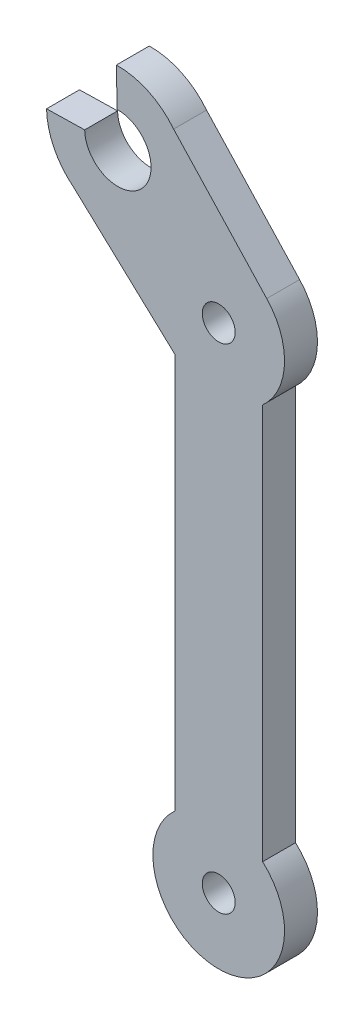
from build123d import *

# Parameters (mm, degrees)
ESQUISSE1_R        = 1.5
BOSS_EXTRU_1_DEPTH = 3


with BuildPart() as part:
    # Esquisse1 → Boss.-Extru.1 (new body)
    with BuildSketch(Plane.XY):
        with BuildLine():
            Line((0, 40.527864045), (0, 4.472135955))
            ThreePointArc((0, 4.472135955), (4, -6), (8, 4.472135955))
            Line((8, 4.472135955), (8, 40.527864045))
            ThreePointArc((8, 40.527864045), (9.994318296, 44.738947964), (8.373640852, 49.107464631))
            Line((8.373640852, 49.107464631), (-0.107464631, 58.241283406))
            ThreePointArc((-0.107464631, 58.241283406), (-2.431884599, 60.07708187), (-5.329514747, 60.690941556))
            Line((-5.329514747, 60.690941556), (-5.256204762, 57.21671493))
            ThreePointArc((-5.256204762, 57.21671493), (-3.098991339, 56.376035281), (-2.168061381, 54.256204762))
            ThreePointArc((-2.168061381, 54.256204762), (-5.128571549, 51.168061381), (-8.21671493, 54.128571549))
            Line((-8.21671493, 54.128571549), (-11.690941556, 54.055261564))
            ThreePointArc((-11.690941556, 54.055261564), (-11.017535525, 51.308353115), (-9.241283406, 49.107464631))
            Line((-9.241283406, 49.107464631), (-0.163194172, 40.679373392))
            Line((-0.163194172, 40.679373392), (0, 40.527864045))
        make_face()
        with Locations((4, 0)):
            Circle(ESQUISSE1_R, mode=Mode.SUBTRACT)
        with Locations((4, 45)):
            Circle(ESQUISSE1_R, mode=Mode.SUBTRACT)
    extrude(amount=BOSS_EXTRU_1_DEPTH)


solid = part.part
